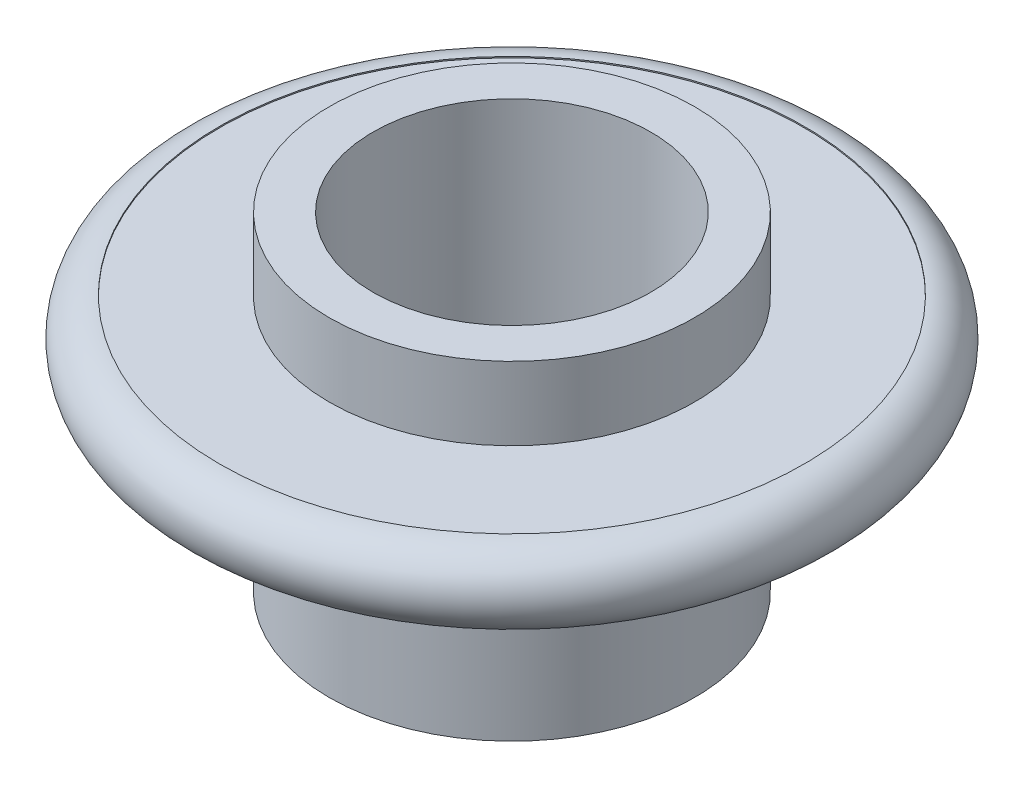
from build123d import *


with BuildPart() as part:
    # Sketch1 → Revolve1 (revolve)
    with BuildSketch(Plane.XY):
        with BuildLine():
            Line((19, 34.18946336), (19, -10.81053664))
            Line((19, -10.81053664), (25, -10.81053664))
            Line((25, -10.81053664), (25, 14.18946336))
            Line((25, 14.18946336), (40, 14.18946336))
            ThreePointArc((40, 14.18946336), (45.084745763, 19.274209123), (40, 24.358954886))
            Line((40, 24.358954886), (40, 24.18946336))
            Line((40, 24.18946336), (25, 24.18946336))
            Line((25, 24.18946336), (25, 34.18946336))
            Line((25, 34.18946336), (19, 34.18946336))
        make_face()
    revolve(axis=Axis((0, 56.797792619, 0), (0, -1, 0)))


solid = part.part
